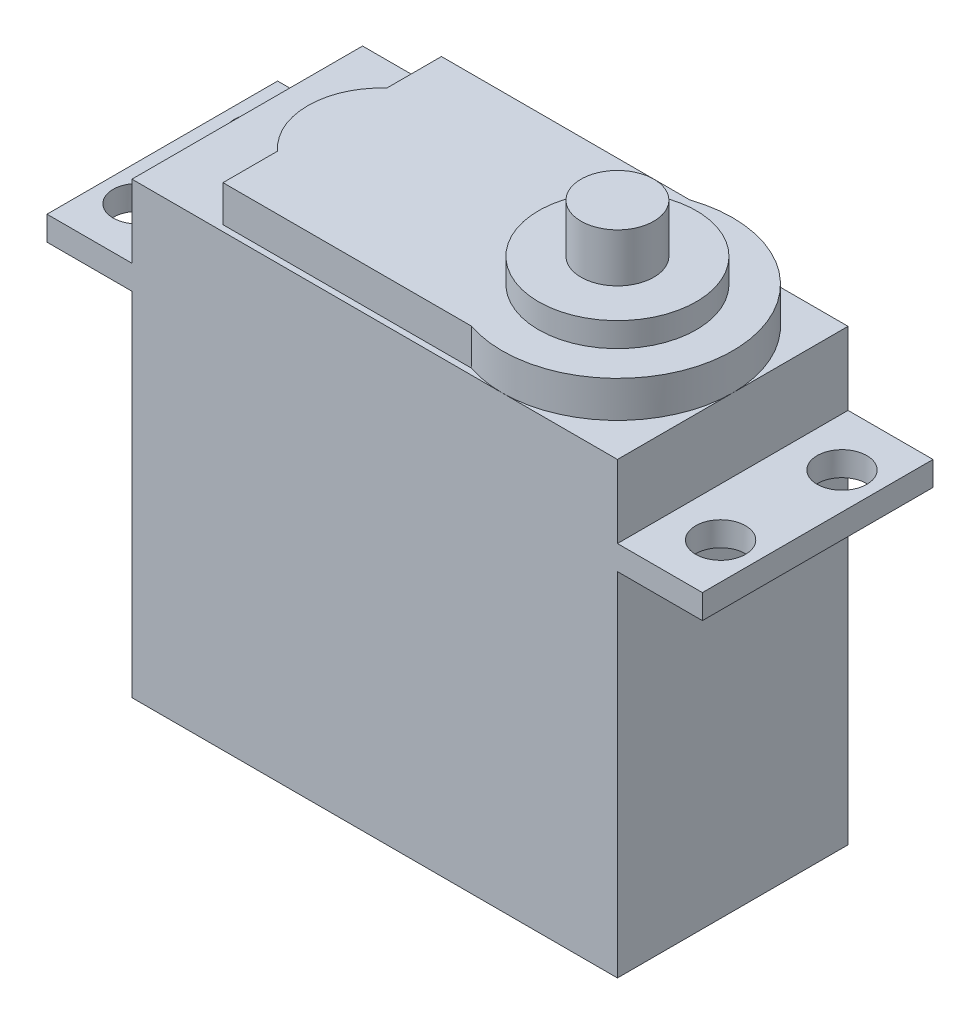
from build123d import *

# Parameters (mm, degrees)
SKETCH1_W           = 40
SKETCH1_H           = 37
BOSS_EXTRUDE1_DEPTH = 19
BOSS_EXTRUDE2_DEPTH = 3
SKETCH3_R           = 6.5
BOSS_EXTRUDE3_DEPTH = 2
SKETCH5_R           = 3
BOSS_EXTRUDE4_DEPTH = 4
SKETCH6_W           = 54
SKETCH6_H           = 19
BOSS_EXTRUDE5_DEPTH = 2
SKETCH7_R           = 2.05
CUT_EXTRUDE1_DEPTH  = 2


with BuildPart() as part:
    # Sketch1 → Boss-Extrude1 (new body)
    with BuildSketch(Plane.XY):
        with Locations((20, 18.5)):
            Rectangle(SKETCH1_W, SKETCH1_H)
    extrude(amount=BOSS_EXTRUDE1_DEPTH)

    # Sketch2 → Boss-Extrude2 (add)
    with BuildSketch(Plane(origin=(0, 37, 0), x_dir=(1, 0, 0), z_dir=(0, 1, 0))):
        with BuildLine():
            Line((7, -0.5), (7, -5))
            ThreePointArc((7, -5), (5, -9.5), (7, -14))
            Line((7, -14), (7, -18.5))
            Line((7, -18.5), (27.458618735, -18.5))
            ThreePointArc((27.458618735, -18.5), (40, -9.5), (27.458618735, -0.5))
            Line((27.458618735, -0.5), (7, -0.5))
        make_face()
    extrude(amount=BOSS_EXTRUDE2_DEPTH)

    # Sketch3 → Boss-Extrude3 (add)
    with BuildSketch(Plane(origin=(0, 40, 0), x_dir=(1, 0, 0), z_dir=(0, 1, 0))):
        with Locations((30.5, -9.5)):
            Circle(SKETCH3_R)
    extrude(amount=BOSS_EXTRUDE3_DEPTH)

    # Sketch5 → Boss-Extrude4 (add)
    with BuildSketch(Plane(origin=(0, 42, 0), x_dir=(1, 0, 0), z_dir=(0, 1, 0))):
        with Locations((30.5, -9.5)):
            Circle(SKETCH5_R)
    extrude(amount=BOSS_EXTRUDE4_DEPTH)

    # Sketch6 → Boss-Extrude5 (add)
    with BuildSketch(Plane(origin=(0, 28.999999912, 0), x_dir=(-1, 0, 0), z_dir=(0, -1, 0))):
        with Locations((-20, -9.5)):
            Rectangle(SKETCH6_W, SKETCH6_H)
    extrude(amount=-BOSS_EXTRUDE5_DEPTH)

    # Sketch7 → Cut-Extrude1 (cut)
    with BuildSketch(Plane(origin=(0, 30.999999912, 0), x_dir=(1, 0, 0), z_dir=(0, 1, 0))):
        with Locations((-4, -4.5)):
            Circle(SKETCH7_R)
        with Locations((-4, -14.5)):
            Circle(SKETCH7_R)
        with Locations((44, -4.5)):
            Circle(SKETCH7_R)
        with Locations((44, -14.5)):
            Circle(SKETCH7_R)
    extrude(amount=-CUT_EXTRUDE1_DEPTH, mode=Mode.SUBTRACT)


solid = part.part
